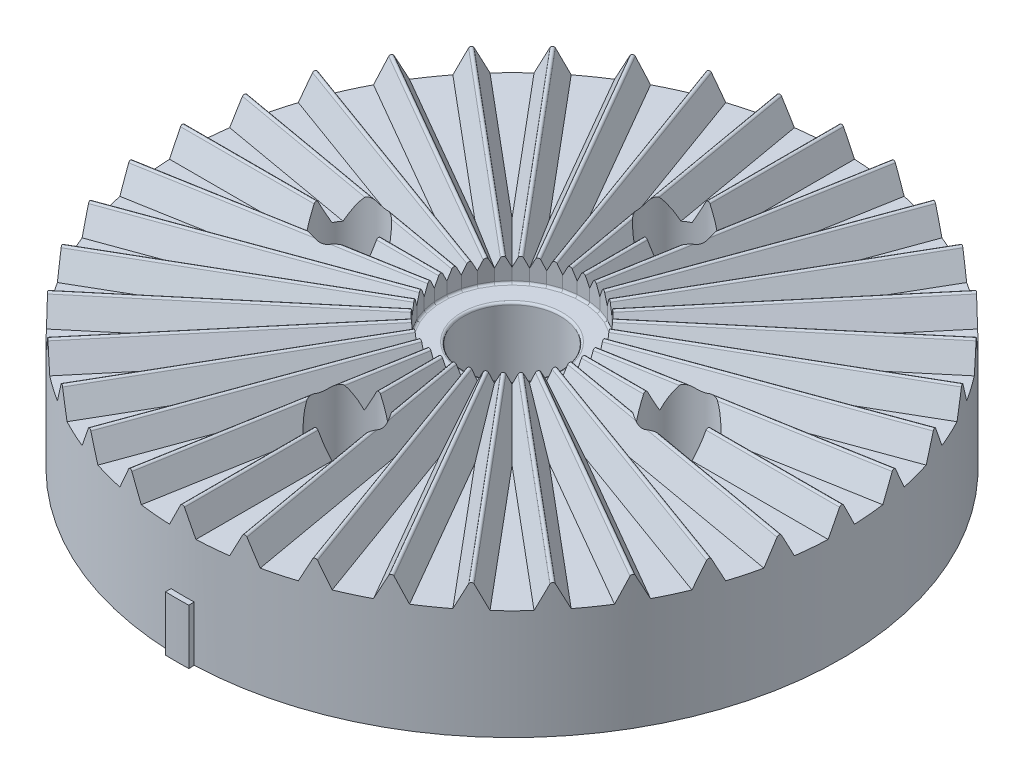
from build123d import *

# Parameters (mm, degrees)
SKETCH1_R                                    = 30
BODY_DEPTH                                   = 10
SKETCH4_R                                    = 4.4
CENTER_HOLE_DEPTH                            = 11
RAIL_DEPTH                                   = 23.5
RAIL_PATTERN_COUNT                           = 36
SKETCH9_W                                    = 2
SKETCH9_H                                    = 20
SKETCH5_W                                    = 0.5
SKETCH5_H                                    = 5
ANGLE_INDICATOR_ANGLE                        = 2
ANGLE_INDICATOR_OTHER_WAY_ANGLE              = 2
SKETCH6_R                                    = 1.6
MOUNTING_HOLE_PATTERN_DEPTH                  = 11.0000001
SKETCH7_R                                    = 2.85
MOUNTING_HOLE_PATTERN_COUNTERBORE_DEPTH      = 3.152786505
MOUNTING_HOLE_PATTERN_COUNTERBORE_DEPTH_BACK = 6
SHAFT_FILLET_R                               = 0.2


with BuildPart() as part:
    # Sketch1 → Body (new body)
    with BuildSketch(Plane(origin=(0, 0, 0), x_dir=(1, 0, 0), z_dir=(0, 1, 0))):
        Circle(SKETCH1_R)
    extrude(amount=BODY_DEPTH)

    # Sketch4 → Center Hole (cut, through all)
    with BuildSketch(Plane(origin=(0, 0, 0), x_dir=(1, 0, 0), z_dir=(0, 1, 0))):
        Circle(SKETCH4_R)
    extrude(amount=CENTER_HOLE_DEPTH, mode=Mode.SUBTRACT)

    # Sketch3 → Rail (add)
    with BuildSketch(Plane(origin=(30, 0, 0), x_dir=(0, 0, -1), z_dir=(1, 0, 0))):
        with BuildLine():
            Line((-1.2, 10), (-0.178885438, 12.042229124))
            ThreePointArc((-0.178885438, 12.042229124), (0, 12.152786405), (0.178885438, 12.042229124))
            Line((0.178885438, 12.042229124), (1.2, 10))
            Line((1.2, 10), (-1.2, 10))
        make_face()
    rail = extrude(amount=-RAIL_DEPTH)

    # Rail Pattern: Rail ×36 about axis
    rail_pattern_axis = Axis((0, 0, 0), (0, 1, 0))
    for i in range(1, RAIL_PATTERN_COUNT):
        add(rail.rotate(rail_pattern_axis, i * 360 / RAIL_PATTERN_COUNT))

    # Sketch9 → Rail Trim (revolve, cut)
    with BuildSketch(Plane.XY):
        with Locations((31, 10)):
            Rectangle(SKETCH9_W, SKETCH9_H)
    revolve(axis=Axis((0, 0, 0), (0, 1, 0)), mode=Mode.SUBTRACT)

    # Sketch5 → Angle Indicator (revolve)
    with BuildSketch(Plane(origin=(0, 0, 0), x_dir=(0, 0, -1), z_dir=(1, 0, 0))):
        with Locations((-30.25, 2.5)):
            Rectangle(SKETCH5_W, SKETCH5_H)
    revolve(axis=Axis((0, 0, 0), (0, 1, 0)), revolution_arc=ANGLE_INDICATOR_ANGLE)

    # Sketch5 → Angle Indicator other way (revolve)
    with BuildSketch(Plane(origin=(0, 0, 0), x_dir=(0, 0, -1), z_dir=(1, 0, 0))):
        with Locations((-30.25, 2.5)):
            Rectangle(SKETCH5_W, SKETCH5_H)
    revolve(axis=Axis((0, 0, 0), (0, -1, 0)), revolution_arc=ANGLE_INDICATOR_OTHER_WAY_ANGLE)

    # Sketch6 → Mounting Hole Pattern (cut, through all)
    with BuildSketch(Plane(origin=(0, 10, 0), x_dir=(1, 0, 0), z_dir=(0, 1, 0))):
        with Locations((0, -15)):
            Circle(SKETCH6_R)
        with Locations((-15, 0)):
            Circle(SKETCH6_R)
        with Locations((0, 15)):
            Circle(SKETCH6_R)
        with Locations((15, 0)):
            Circle(SKETCH6_R)
    extrude(amount=-MOUNTING_HOLE_PATTERN_DEPTH, mode=Mode.SUBTRACT)

    # Sketch7 → Mounting Hole Pattern Counterbore (cut, two sides)
    with BuildSketch(Plane(origin=(0, 10, 0), x_dir=(1, 0, 0), z_dir=(0, 1, 0))) as mounting_hole_pattern_counterbore_sk:
        with Locations((0, 15)):
            Circle(SKETCH7_R)
        with Locations((15, 0)):
            Circle(SKETCH7_R)
        with Locations((0, -15)):
            Circle(SKETCH7_R)
        with Locations((-15, 0)):
            Circle(SKETCH7_R)
    extrude(amount=MOUNTING_HOLE_PATTERN_COUNTERBORE_DEPTH, mode=Mode.SUBTRACT)
    extrude(mounting_hole_pattern_counterbore_sk.sketch, amount=-MOUNTING_HOLE_PATTERN_COUNTERBORE_DEPTH_BACK, mode=Mode.SUBTRACT)

    # Shaft Fillet
    shaft_fillet_edges = [part.edges().sort_by_distance(p)[0] for p in [
        (6.401250395, 10, -1.128713155),
        (6.108002035, 10, -2.223130932),
        (5.629165125, 10, -3.25),
        (4.97928888, 10, -4.178119463),
        (4.178119463, 10, -4.97928888),
        (3.25, 10, -5.629165125),
        (2.223130932, 10, -6.108002035),
        (1.128713155, 10, -6.401250395),
        (0, 10, -6.5),
        (-1.128713155, 10, -6.401250395),
        (-2.223130932, 10, -6.108002035),
        (-3.25, 10, -5.629165125),
        (-4.178119463, 10, -4.97928888),
        (-4.97928888, 10, -4.178119463),
        (-5.629165125, 10, -3.25),
        (-6.108002035, 10, -2.223130932),
        (-6.401250395, 10, -1.128713155),
        (-6.5, 10, 0),
        (-6.401250395, 10, 1.128713155),
        (-6.108002035, 10, 2.223130932),
        (-5.629165125, 10, 3.25),
        (-4.97928888, 10, 4.178119463),
        (-4.178119463, 10, 4.97928888),
        (-3.25, 10, 5.629165125),
        (-2.223130932, 10, 6.108002035),
        (-1.128713155, 10, 6.401250395),
        (0, 10, 6.5),
        (1.128713155, 10, 6.401250395),
        (2.223130932, 10, 6.108002035),
        (3.25, 10, 5.629165125),
        (4.178119463, 10, 4.97928888),
        (4.97928888, 10, 4.178119463),
        (5.629165125, 10, 3.25),
        (6.108002035, 10, 2.223130932),
        (6.401250395, 10, 1.128713155),
        (6.5, 10, 0),
        (-4.4, 10, 0),
    ]]
    fillet(shaft_fillet_edges, radius=SHAFT_FILLET_R)


solid = part.part
